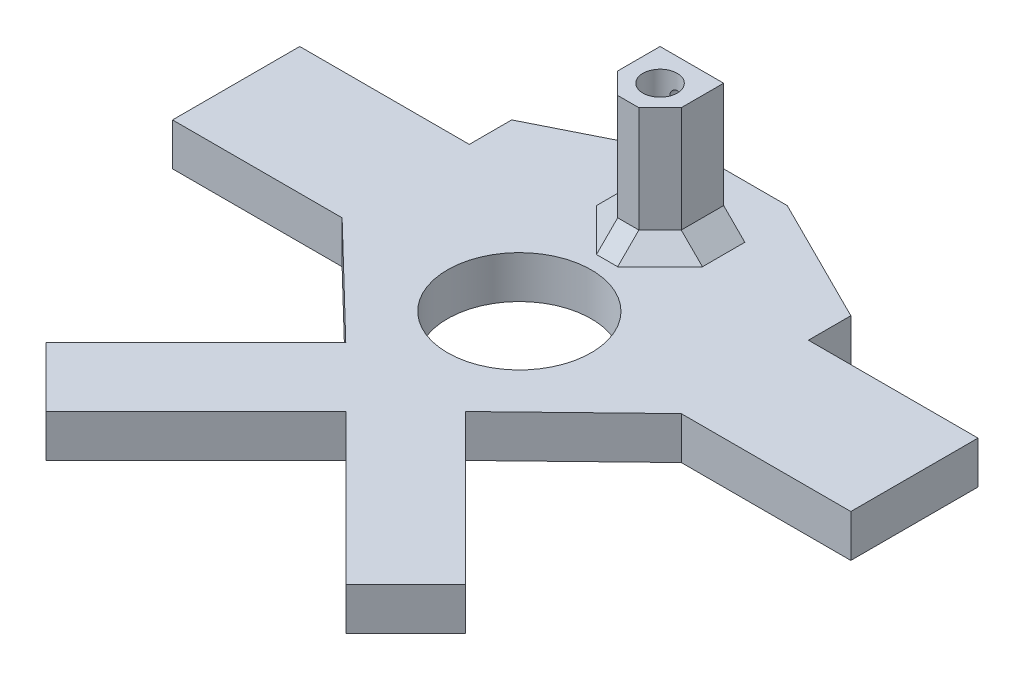
from build123d import *

# Parameters (mm, degrees)
SKETCH1_W           = 40
SKETCH1_H           = 30
BOSS_EXTRUDE1_DEPTH = 10
SKETCH2_R           = 4.05
CUT_EXTRUDE1_DEPTH  = 10
SKETCH3_W           = 15
SKETCH3_H           = 15
SKETCH3_R           = 4.05
BOSS_EXTRUDE2_DEPTH = 30
SKETCH4_R           = 1.45
CUT_EXTRUDE2_DEPTH  = 5
CHAMFER1_SIZE       = 5
SKETCH5_R           = 16.957046222
CUT_EXTRUDE3_DEPTH  = 10


with BuildPart() as part:
    # Sketch1 → Boss-Extrude1 (new body)
    with BuildSketch(Plane(origin=(0, 0, 0), x_dir=(1, 0, 0), z_dir=(0, 1, 0))):
        Polygon((14.142135624, -40), (0, -40), (7.071067812, -47.071067812), (0, -54.142135624), (35.355339059, -89.497474683), (49.497474683, -75.355339059), align=None)
        Polygon((7.071067812, -47.071067812), (0, -40), (-7.071067812, -47.071067812), (0, -54.142135624), align=None)
        Polygon((0, -40), (-14.142135624, -40), (-49.497474683, -75.355339059), (-35.355339059, -89.497474683), (0, -54.142135624), (-7.071067812, -47.071067812), align=None)
        Polygon((10, 40), (-10, 40), (-40, 25), (-40, 15), (-40, -15), (-14.142135624, -40), (-7.071067812, -32.928932188), (0, -40), (7.071067812, -32.928932188), (14.142135624, -40), (40, -15), (40, 15), (40, 25), align=None)
        Polygon((7.071067812, -32.928932188), (0, -40), (14.142135624, -40), align=None)
        Polygon((-7.071067812, -32.928932188), (-14.142135624, -40), (0, -40), align=None)
        with Locations((-60, 0)):
            Rectangle(SKETCH1_W, SKETCH1_H)
        with Locations((60, 0)):
            Rectangle(SKETCH1_W, SKETCH1_H)
    extrude(amount=BOSS_EXTRUDE1_DEPTH)

    # Sketch2 → Cut-Extrude1 (cut)
    with BuildSketch(Plane(origin=(0, 10, 0), x_dir=(1, 0, 0), z_dir=(0, 1, 0))):
        with Locations((0, 20)):
            Circle(SKETCH2_R)
    extrude(amount=-CUT_EXTRUDE1_DEPTH, mode=Mode.SUBTRACT)

    # Sketch3 → Boss-Extrude2 (add)
    with BuildSketch(Plane(origin=(0, 10, 0), x_dir=(1, 0, 0), z_dir=(0, 1, 0))):
        with Locations((0, 20)):
            Rectangle(SKETCH3_W, SKETCH3_H)
        with Locations((0, 20)):
            Circle(SKETCH3_R, mode=Mode.SUBTRACT)
    extrude(amount=BOSS_EXTRUDE2_DEPTH)

    # Sketch4 → Cut-Extrude2 (cut)
    with BuildSketch(Plane(origin=(0, 0, -27.5), x_dir=(-1, 0, 0), z_dir=(0, 0, -1))):
        with Locations((0, 35)):
            Circle(SKETCH4_R)
        with Locations((0, 20)):
            Circle(SKETCH4_R)
    extrude(amount=-CUT_EXTRUDE2_DEPTH, mode=Mode.SUBTRACT)

    # Chamfer1
    chamfer1_edges = [part.edges().sort_by_distance(p)[0] for p in [
        (7.5, 10, -20),
        (7.5, 25, -12.5),
        (-7.5, 10, -20),
        (0, 10, -12.5),
        (-7.5, 25, -12.5),
    ]]
    chamfer(chamfer1_edges, length=CHAMFER1_SIZE)

    # Sketch5 → Cut-Extrude3 (cut)
    with BuildSketch(Plane(origin=(0, 10, 0), x_dir=(1, 0, 0), z_dir=(0, 1, 0))):
        with Locations((0, -13.19116881)):
            Circle(SKETCH5_R)
    extrude(amount=-CUT_EXTRUDE3_DEPTH, mode=Mode.SUBTRACT)


solid = part.part
